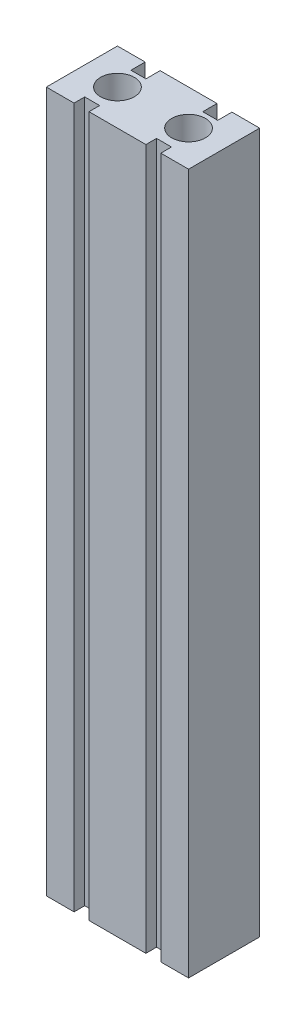
from build123d import *

# Parameters (mm, degrees)
SKETCH_2_W          = 40
SKETCH_2_H          = 20
EXTRUDE_1_DEPTH     = 197
SKETCH_3_R          = 4.75
CUT_EXTRUDE_1_DEPTH = 198
SKETCH_4_W          = 4.2
SKETCH_4_H          = 197
CUT_EXTRUDE_2_DEPTH = 3
SKETCH_5_W          = 4.2
SKETCH_5_H          = 197
CUT_EXTRUDE_3_DEPTH = 4


with BuildPart() as part:
    # 草图2 → 凸台-拉伸1 (new body)
    with BuildSketch(Plane(origin=(0, 0, 0), x_dir=(1, 0, 0), z_dir=(0, 1, 0))):
        Rectangle(SKETCH_2_W, SKETCH_2_H)
    extrude(amount=EXTRUDE_1_DEPTH)

    # 草图3 → 切除-拉伸1 (cut, through all)
    with BuildSketch(Plane.XZ):
        with Locations((-10, 0)):
            Circle(SKETCH_3_R)
        with Locations((10, 0)):
            Circle(SKETCH_3_R)
    extrude(amount=-CUT_EXTRUDE_1_DEPTH, mode=Mode.SUBTRACT)

    # 草图4 → 切除-拉伸2 (cut)
    with BuildSketch(Plane.XY.offset(10)):
        with Locations((-10.1, 98.5)):
            Rectangle(SKETCH_4_W, SKETCH_4_H)
        with Locations((10.1, 98.5)):
            Rectangle(SKETCH_4_W, SKETCH_4_H)
    extrude(amount=-CUT_EXTRUDE_2_DEPTH, mode=Mode.SUBTRACT)

    # 草图5 → 切除-拉伸3 (cut)
    with BuildSketch(Plane(origin=(0, 0, -10), x_dir=(-1, 0, 0), z_dir=(0, 0, -1))):
        with Locations((-10.1, 98.5)):
            Rectangle(SKETCH_5_W, SKETCH_5_H)
        with Locations((10.1, 98.5)):
            Rectangle(SKETCH_5_W, SKETCH_5_H)
    extrude(amount=-CUT_EXTRUDE_3_DEPTH, mode=Mode.SUBTRACT)


solid = part.part
